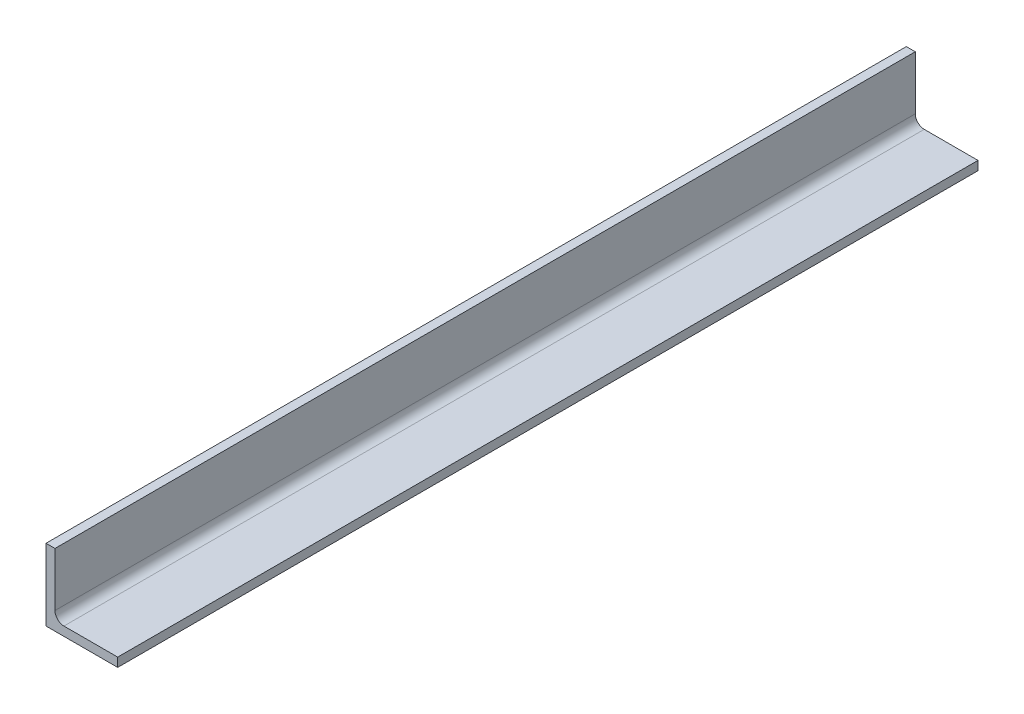
from build123d import *

# Parameters (mm, degrees)
BOSS_EXTRUDE1_DEPTH = 304.8


with BuildPart() as part:
    # Sketch2 → Boss-Extrude1 (new body, symmetric)
    with BuildSketch(Plane.XY):
        with BuildLine():
            Line((0, 0), (0, 50.8))
            Line((0, 50.8), (6.35, 50.8))
            Line((6.35, 50.8), (6.35, 12.7))
            ThreePointArc((6.35, 12.7), (8.209871939, 8.209871939), (12.7, 6.35))
            Line((12.7, 6.35), (50.8, 6.35))
            Line((50.8, 6.35), (50.8, 0))
            Line((50.8, 0), (0, 0))
        make_face()
    extrude(amount=BOSS_EXTRUDE1_DEPTH, both=True)


solid = part.part
